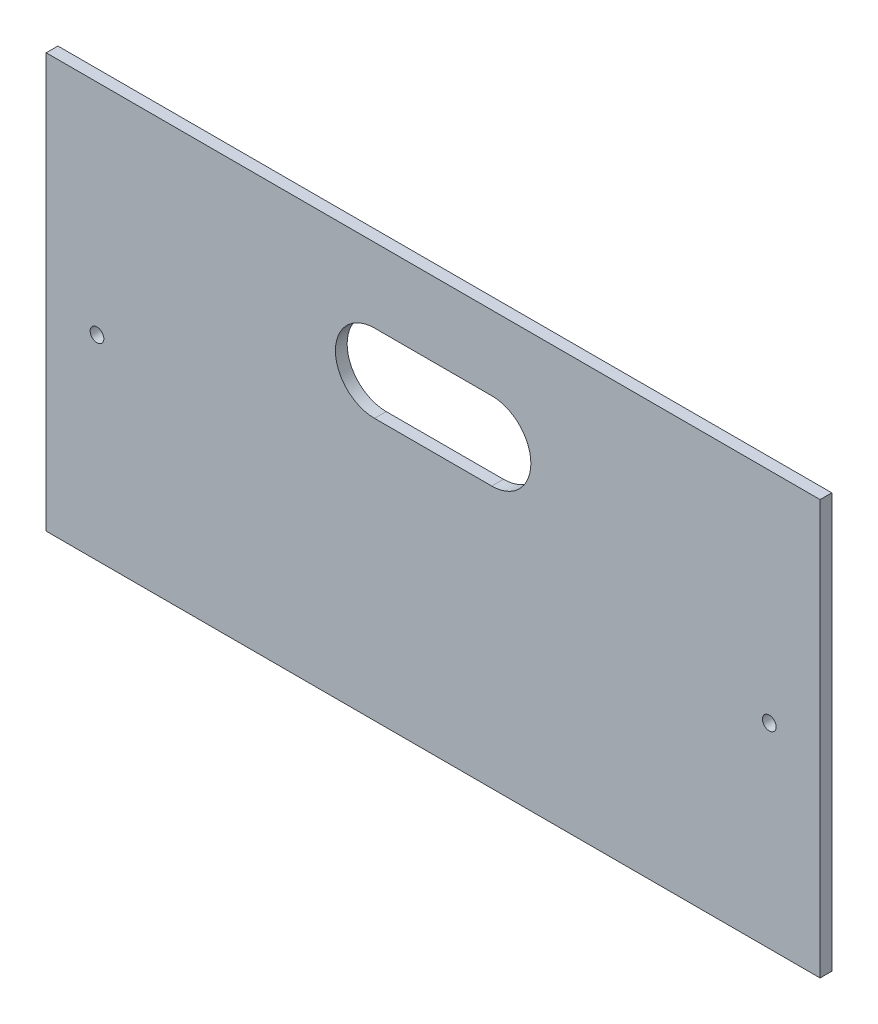
from build123d import *

# Parameters (mm, degrees)
ESQUISSE1_W             = 198
ESQUISSE1_H             = 106
ESQUISSE1_R             = 1.75
BOSS_EXTRU_1_DEPTH      = 3
ENL_V_MAT_EXTRU_1_DEPTH = 4


with BuildPart() as part:
    # Esquisse1 → Boss.-Extru.1 (new body)
    with BuildSketch(Plane.XY):
        Rectangle(ESQUISSE1_W, ESQUISSE1_H)
        with Locations((-86, -3)):
            Circle(ESQUISSE1_R, mode=Mode.SUBTRACT)
        with Locations((86, -3)):
            Circle(ESQUISSE1_R, mode=Mode.SUBTRACT)
    extrude(amount=BOSS_EXTRU_1_DEPTH)

    # Esquisse2 → Enlèv. mat.-Extru.1 (cut, through all)
    with BuildSketch(Plane(origin=(0, 0, 0), x_dir=(-1, 0, 0), z_dir=(0, 0, -1))):
        with BuildLine():
            Line((-15, 34), (15, 34))
            ThreePointArc((15, 34), (25, 24), (15, 14))
            Line((15, 14), (-15, 14))
            ThreePointArc((-15, 14), (-25, 24), (-15, 34))
        make_face()
    extrude(amount=-ENL_V_MAT_EXTRU_1_DEPTH, mode=Mode.SUBTRACT)


solid = part.part
